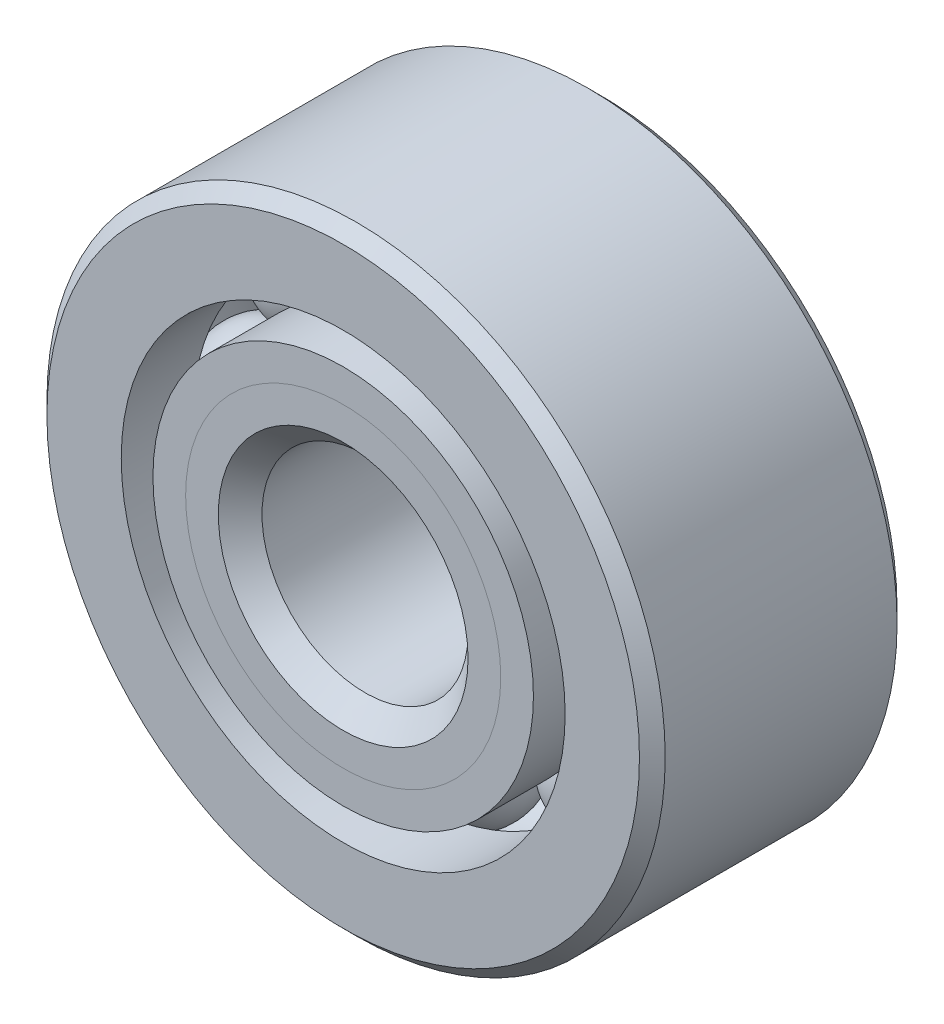
from build123d import *

# Parameters (mm, degrees)
CIRPATTERN1_COUNT = 8


with BuildPart() as part:
    # Sketch1 → Revolve1 (revolve)
    with BuildSketch(Plane(origin=(0, 0, 0), x_dir=(0, 0, -1), z_dir=(1, 0, 0))):
        with BuildLine():
            Line((1.7859375, 4.7625), (-1.7859375, 4.7625))
            Line((-1.7859375, 4.7625), (-1.984375, 4.5640625))
            Line((-1.984375, 4.5640625), (-1.984375, 3.419230769))
            Line((-1.984375, 3.419230769), (-0.881944444, 3.419230769))
            ThreePointArc((-0.881944444, 3.419230769), (0, 4.090136422), (0.881944444, 3.419230769))
            Line((0.881944444, 3.419230769), (1.984375, 3.419230769))
            Line((1.984375, 3.419230769), (1.984375, 4.5640625))
            Line((1.984375, 4.5640625), (1.7859375, 4.7625))
        make_face()
    revolve(axis=Axis((0, 0, 1.984375), (0, 0, -1)))


with BuildPart() as body_2:
    # Sketch2 → Revolve2 (revolve)
    with BuildSketch(Plane(origin=(0, 0, 0), x_dir=(0, 0, -1), z_dir=(1, 0, 0))):
        with BuildLine():
            Line((-1.984375, 2.930769231), (-0.881944444, 2.930769231))
            ThreePointArc((-0.881944444, 2.930769231), (-0.554062361, 2.446652849), (0, 2.259863578))
            Line((0, 2.259863578), (0, 1.923681789))
            Line((0, 1.923681789), (-1.480831279, 1.923681789))
            Line((-1.480831279, 1.923681789), (-1.984375, 2.42722551))
            Line((-1.984375, 2.42722551), (-1.984375, 2.930769231))
        make_face()
    revolve(axis=Axis((0, 0, 1.984375), (0, 0, -1)))


with BuildPart() as body_3:
    # Sketch3 → Revolve3 (revolve)
    with BuildSketch(Plane(origin=(0, 0, 0), x_dir=(0, 0, -1), z_dir=(1, 0, 0))):
        with BuildLine():
            Line((-1.984375, 2.42722551), (-1.480831279, 1.923681789))
            Line((-1.480831279, 1.923681789), (0, 1.923681789))
            Line((0, 1.923681789), (0, 2.259863578))
            ThreePointArc((0, 2.259863578), (0.554062361, 2.446652849), (0.881944444, 2.930769231))
            Line((0.881944444, 2.930769231), (1.984375, 2.930769231))
            Line((1.984375, 2.930769231), (1.984375, 1.7859375))
            Line((1.984375, 1.7859375), (1.7859375, 1.5875))
            Line((1.7859375, 1.5875), (-1.648193211, 1.5875))
            Line((-1.648193211, 1.5875), (-1.984375, 1.923681789))
            Line((-1.984375, 1.923681789), (-1.984375, 2.42722551))
        make_face()
    revolve(axis=Axis((0, 0, 1.984375), (0, 0, -1)))


with BuildPart() as body_4:
    # Sketch4 → Revolve4 (revolve)
    with BuildSketch(Plane(origin=(0, 0, 0), x_dir=(0, 0, -1), z_dir=(1, 0, 0))):
        with BuildLine():
            Line((-0.915136422, 3.175), (0.915136422, 3.175))
            ThreePointArc((0.915136422, 3.175), (0, 4.090136422), (-0.915136422, 3.175))
        make_face()
    revolve(axis=Axis((0, 3.175, 0.915136422), (0, 0, -1)))


with BuildPart() as cirpattern1_1:
    # CirPattern1: pattern copy
    add(body_4.part.rotate(Axis((0, 0, -1.984375), (0, 0, 1)), 1 * 360 / CIRPATTERN1_COUNT))


with BuildPart() as cirpattern1_2:
    # CirPattern1: pattern copy
    add(body_4.part.rotate(Axis((0, 0, -1.984375), (0, 0, 1)), 2 * 360 / CIRPATTERN1_COUNT))


with BuildPart() as cirpattern1_3:
    # CirPattern1: pattern copy
    add(body_4.part.rotate(Axis((0, 0, -1.984375), (0, 0, 1)), 3 * 360 / CIRPATTERN1_COUNT))


with BuildPart() as cirpattern1_4:
    # CirPattern1: pattern copy
    add(body_4.part.rotate(Axis((0, 0, -1.984375), (0, 0, 1)), 4 * 360 / CIRPATTERN1_COUNT))


with BuildPart() as cirpattern1_5:
    # CirPattern1: pattern copy
    add(body_4.part.rotate(Axis((0, 0, -1.984375), (0, 0, 1)), 5 * 360 / CIRPATTERN1_COUNT))


with BuildPart() as cirpattern1_6:
    # CirPattern1: pattern copy
    add(body_4.part.rotate(Axis((0, 0, -1.984375), (0, 0, 1)), 6 * 360 / CIRPATTERN1_COUNT))


with BuildPart() as cirpattern1_7:
    # CirPattern1: pattern copy
    add(body_4.part.rotate(Axis((0, 0, -1.984375), (0, 0, 1)), 7 * 360 / CIRPATTERN1_COUNT))


solid = Compound([part.part, body_2.part, body_3.part, body_4.part, cirpattern1_1.part, cirpattern1_2.part, cirpattern1_3.part, cirpattern1_4.part, cirpattern1_5.part, cirpattern1_6.part, cirpattern1_7.part])
